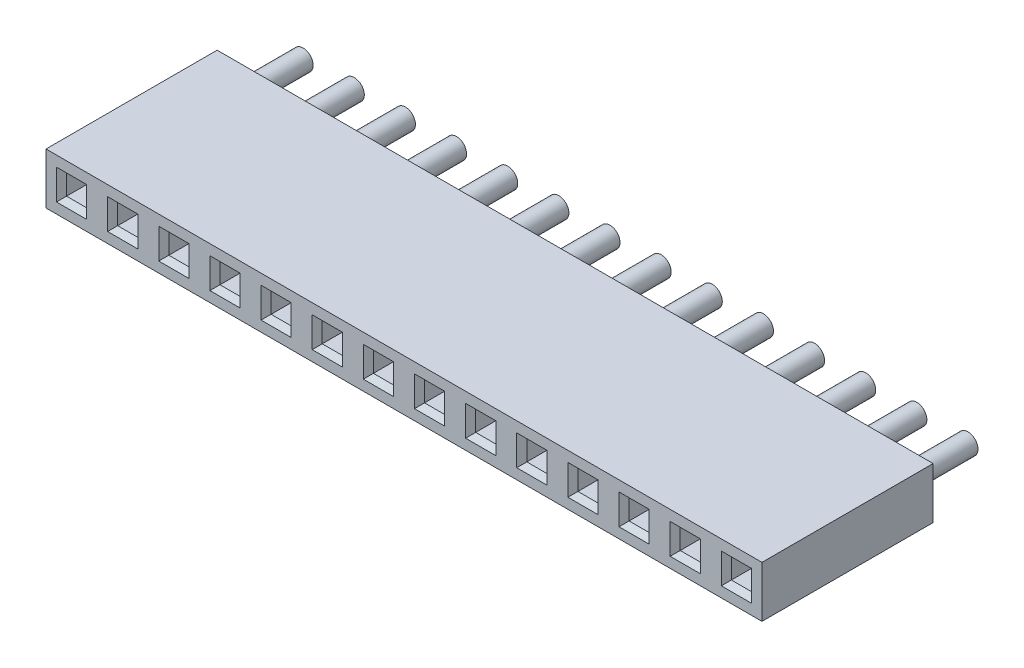
from build123d import *

# Parameters (mm, degrees)
SKETCH1_W                  = 35.56
SKETCH1_H                  = 2.54
BOSS_EXTRUDE1_DEPTH        = 8.5
SKETCH2_W                  = 1
SKETCH2_H                  = 1
CUT_EXTRUDE1_DEPTH         = 8
CHAMFER1_SIZE              = 0.25
LPATTERN2_COUNT            = 14
LPATTERN2_PITCH            = 2.54
CHAMFER1_OF_LPATTERN2_SIZE = 0.25
SKETCH3_R                  = 0.5
BOSS_EXTRUDE2_DEPTH        = 3
LPATTERN3_COUNT            = 14
LPATTERN3_PITCH            = 2.54


with BuildPart() as part:
    # Sketch1 → Boss-Extrude1 (new body)
    with BuildSketch(Plane.XY):
        with Locations((17.78, 1.27)):
            Rectangle(SKETCH1_W, SKETCH1_H)
    extrude(amount=BOSS_EXTRUDE1_DEPTH)

    # Sketch2 → Cut-Extrude1 (cut)
    with BuildSketch(Plane.XY.offset(8.5)):
        with Locations((1.27, 1.27)):
            Rectangle(SKETCH2_W, SKETCH2_H)
    cut_extrude1 = extrude(amount=-CUT_EXTRUDE1_DEPTH, mode=Mode.SUBTRACT)

    # Chamfer1
    chamfer1_edges = [part.edges().sort_by_distance(p)[0] for p in [
        (0.77, 1.27, 8.5),
        (1.27, 0.77, 8.5),
        (1.77, 1.27, 8.5),
        (1.27, 1.77, 8.5),
    ]]
    chamfer(chamfer1_edges, length=CHAMFER1_SIZE)

    # LPattern2: Cut-Extrude1 ×14
    with Locations(*[(i * LPATTERN2_PITCH, 0, 0) for i in range(1, LPATTERN2_COUNT)]):
        add(cut_extrude1, mode=Mode.SUBTRACT)

    # Chamfer1 of LPattern2
    chamfer1_of_lpattern2_edges = [part.edges().sort_by_distance(p)[0] for p in [
        (3.31, 1.27, 8.5),
        (3.81, 0.77, 8.5),
        (4.31, 1.27, 8.5),
        (3.81, 1.77, 8.5),
        (5.85, 1.27, 8.5),
        (6.35, 0.77, 8.5),
        (6.85, 1.27, 8.5),
        (6.35, 1.77, 8.5),
        (8.39, 1.27, 8.5),
        (8.89, 0.77, 8.5),
        (9.39, 1.27, 8.5),
        (8.89, 1.77, 8.5),
        (10.93, 1.27, 8.5),
        (11.43, 0.77, 8.5),
        (11.93, 1.27, 8.5),
        (11.43, 1.77, 8.5),
        (13.47, 1.27, 8.5),
        (13.97, 0.77, 8.5),
        (14.47, 1.27, 8.5),
        (13.97, 1.77, 8.5),
        (16.01, 1.27, 8.5),
        (16.51, 0.77, 8.5),
        (17.01, 1.27, 8.5),
        (16.51, 1.77, 8.5),
        (18.55, 1.27, 8.5),
        (19.05, 0.77, 8.5),
        (19.55, 1.27, 8.5),
        (19.05, 1.77, 8.5),
        (21.09, 1.27, 8.5),
        (21.59, 0.77, 8.5),
        (22.09, 1.27, 8.5),
        (21.59, 1.77, 8.5),
        (23.63, 1.27, 8.5),
        (24.13, 0.77, 8.5),
        (24.63, 1.27, 8.5),
        (24.13, 1.77, 8.5),
        (26.17, 1.27, 8.5),
        (26.67, 0.77, 8.5),
        (27.17, 1.27, 8.5),
        (26.67, 1.77, 8.5),
        (28.71, 1.27, 8.5),
        (29.21, 0.77, 8.5),
        (29.71, 1.27, 8.5),
        (29.21, 1.77, 8.5),
        (31.25, 1.27, 8.5),
        (31.75, 0.77, 8.5),
        (32.25, 1.27, 8.5),
        (31.75, 1.77, 8.5),
        (33.79, 1.27, 8.5),
        (34.29, 0.77, 8.5),
        (34.79, 1.27, 8.5),
        (34.29, 1.77, 8.5),
    ]]
    chamfer(chamfer1_of_lpattern2_edges, length=CHAMFER1_OF_LPATTERN2_SIZE)

    # Sketch3 → Boss-Extrude2 (add)
    with BuildSketch(Plane(origin=(0, 0, 0), x_dir=(-1, 0, 0), z_dir=(0, 0, -1))):
        with Locations((-1.27, 1.27)):
            Circle(SKETCH3_R)
    boss_extrude2 = extrude(amount=BOSS_EXTRUDE2_DEPTH)

    # LPattern3: Boss-Extrude2 ×14
    with Locations(*[(i * LPATTERN3_PITCH, 0, 0) for i in range(1, LPATTERN3_COUNT)]):
        add(boss_extrude2)


solid = part.part
